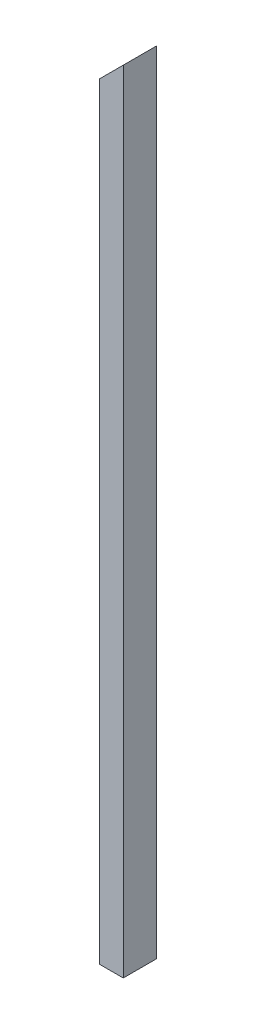
from build123d import *

# Parameters (mm, degrees)
BOSS_EXTRUDE1_DEPTH = 88.9


with BuildPart() as part:
    # Sketch3 → Boss-Extrude1 (new body)
    with BuildSketch(Plane.XY):
        Polygon((0, 0), (0, 2057.4), (63.5, 2120.9), (63.5, 0), align=None)
    extrude(amount=BOSS_EXTRUDE1_DEPTH)


solid = part.part
